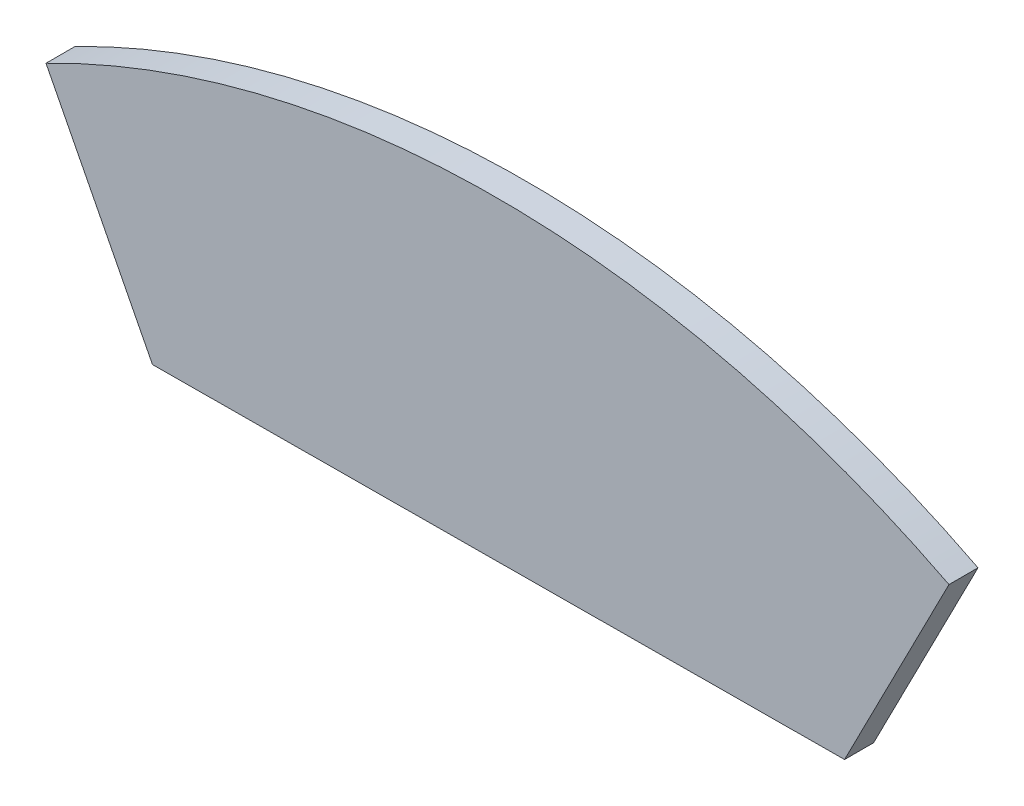
from build123d import *

# Parameters (mm, degrees)
BOSS_EXTRUDE1_DEPTH = 3.175


with BuildPart() as part:
    # Sketch1 → Boss-Extrude1 (new body)
    with BuildSketch(Plane.XY):
        with BuildLine():
            Line((-49.380842801, 96.360567986), (-37.737582209, 73.640194249))
            Line((-37.737582209, 73.640194249), (37.961160549, 74.076479551))
            Line((37.961160549, 74.076479551), (49.380842801, 96.360567986))
            ThreePointArc((49.380842801, 96.360567986), (0, 108.2766212), (-49.380842801, 96.360567986))
        make_face()
    extrude(amount=BOSS_EXTRUDE1_DEPTH)


solid = part.part
